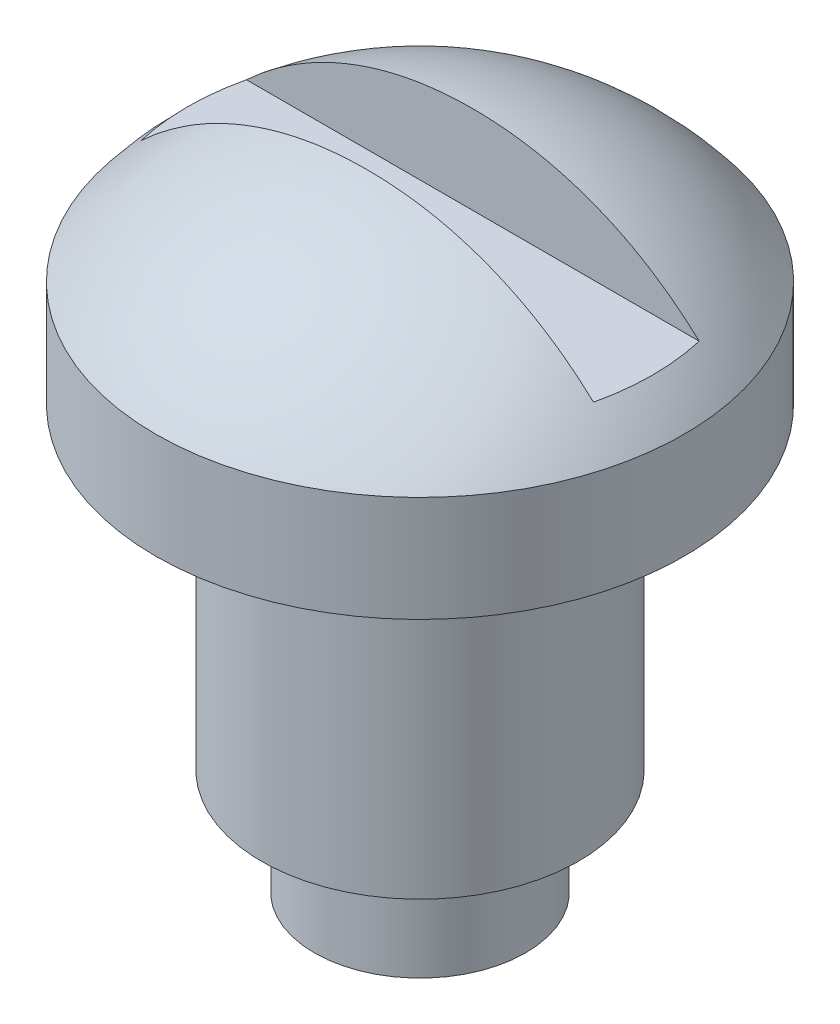
from build123d import *

# Parameters (mm, degrees)
KES_EKSTR_ZYON12_START = -4.399452
IZIM9_W                = 2
IZIM9_H                = 1.732554961
KES_EKSTR_ZYON12_DEPTH = 8.798904


with BuildPart() as part:
    # Çizim2 → Döndür3 (revolve)
    with BuildSketch(Plane.XY):
        with BuildLine():
            Line((0, 0), (2, 0))
            Line((2, 0), (2, 2))
            Line((2, 2), (3, 2))
            Line((3, 2), (3, 8))
            Line((3, 8), (5, 8))
            Line((5, 8), (5, 10))
            ThreePointArc((5, 10), (2.783322768, 11.790255766), (0, 12.4))
            Line((0, 12.4), (0, 0))
        make_face()
    revolve(axis=Axis((0, 0, 0), (0, 1, 0)))

    # Çizim9 → Kes-Ekstrüzyon12 (cut)
    with BuildSketch(Plane(origin=(0, 0, 0), x_dir=(0, 0, -1), z_dir=(1, 0, 0)).offset(KES_EKSTR_ZYON12_START)):
        with Locations((0, 11.53453533)):
            Rectangle(IZIM9_W, IZIM9_H)
    kes_ekstr_zyon12 = extrude(amount=KES_EKSTR_ZYON12_DEPTH, mode=Mode.SUBTRACT)

    # Aynalama2: Kes-Ekstrüzyon12 across plane
    add(kes_ekstr_zyon12.mirror(Plane(origin=(0, 0, 0), x_dir=(0, 0, 1), z_dir=(1, 0, 0))), mode=Mode.SUBTRACT)


solid = part.part
